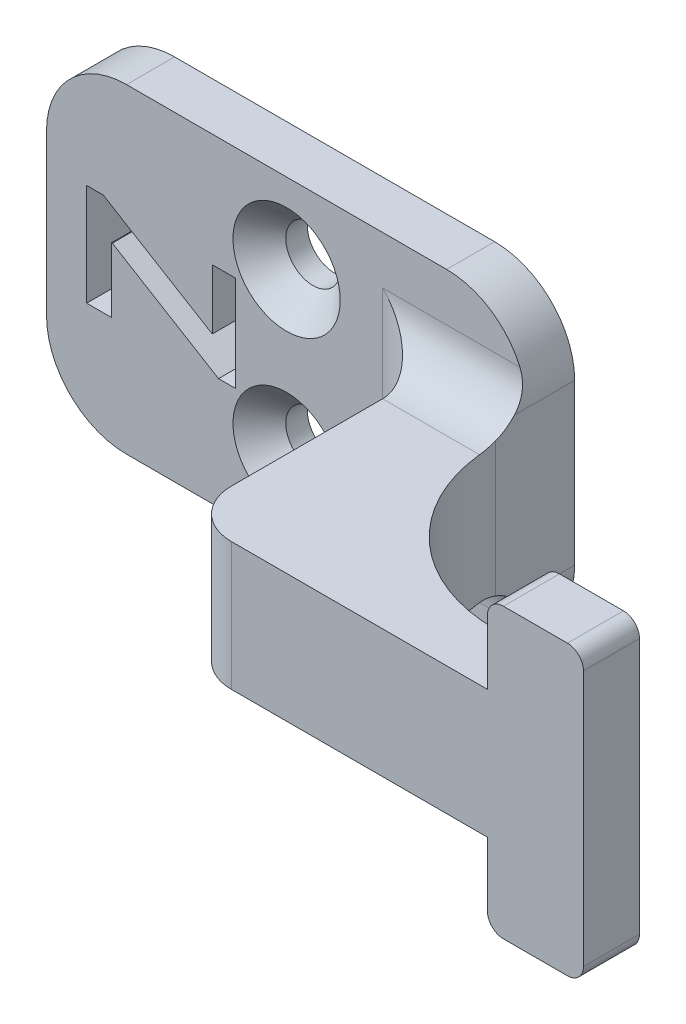
from build123d import *

# Parameters (mm, degrees)
BOSS_EXTRUDE1_DEPTH                                 = 3
BOSS_EXTRUDE2_DEPTH                                 = 4
SKETCH3_W                                           = 6
SKETCH3_H                                           = 5
BOSS_EXTRUDE3_DEPTH                                 = 3.5
FILLET1_R                                           = 3
FILLET3_R                                           = 10
CSK_FOR_M3_COUNTERSUNK_FLAT_HEAD_SCREW1_D           = 3.4
CSK_FOR_M3_COUNTERSUNK_FLAT_HEAD_SCREW1_DEPTH       = 20
CSK_FOR_M3_COUNTERSUNK_FLAT_HEAD_SCREW1_CSINK_D     = 6.7
CSK_FOR_M3_COUNTERSUNK_FLAT_HEAD_SCREW1_CSINK_ANGLE = 90
CSK_FOR_M3_COUNTERSUNK_FLAT_HEAD_SCREW1_TIP         = 1.021463052
CUT_EXTRUDE1_DEPTH                                  = 10
FILLET4_R                                           = 1


with BuildPart() as part:
    # Sketch1 → Boss-Extrude1 (new body)
    with BuildSketch(Plane.XY):
        with BuildLine():
            Line((-10, -10), (10, -10))
            ThreePointArc((10, -10), (13.535533906, -8.535533906), (15, -5))
            Line((15, -5), (15, 5))
            ThreePointArc((15, 5), (13.535533906, 8.535533906), (10, 10))
            Line((10, 10), (-10, 10))
            ThreePointArc((-10, 10), (-13.535533906, 8.535533906), (-15, 5))
            Line((-15, 5), (-15, -5))
            ThreePointArc((-15, -5), (-13.535533906, -8.535533906), (-10, -10))
        make_face()
    extrude(amount=BOSS_EXTRUDE1_DEPTH)

    # Sketch2 → Boss-Extrude2 (add, symmetric)
    with BuildSketch(Plane(origin=(0, 0, 0), x_dir=(1, 0, 0), z_dir=(0, 1, 0))):
        Polygon((15, 0), (15, -14.95), (34, -14.95), (34, -18.45), (9, -18.45), (9, 0), align=None)
    extrude(amount=BOSS_EXTRUDE2_DEPTH, both=True)

    # Sketch3 → Boss-Extrude3 (add)
    with BuildSketch(Plane.XY.offset(18.45)):
        with Locations((31, 6.5)):
            Rectangle(SKETCH3_W, SKETCH3_H)
        with Locations((31, -6.5)):
            Rectangle(SKETCH3_W, SKETCH3_H)
    extrude(amount=-BOSS_EXTRUDE3_DEPTH)

    # Fillet1
    fillet1_edges = [part.edges().sort_by_distance(p)[0] for p in [
        (12, 4, 3),
        (9, 0, 3),
        (12, -4, 3),
        (9, 0, 18.45),
    ]]
    fillet(fillet1_edges, radius=FILLET1_R)

    # Fillet3
    fillet3_edges = [part.edges().sort_by_distance(p)[0] for p in [
        (15, 0, 14.95),
    ]]
    fillet(fillet3_edges, radius=FILLET3_R)

    # CSK for M3 Countersunk Flat Head Screw1
    with Locations(Plane(origin=(0, 5, 3), x_dir=(1, 0, 0), z_dir=(0, 0, 1))):
        with Locations((0, 0), (0, -10)):
            CounterSinkHole(CSK_FOR_M3_COUNTERSUNK_FLAT_HEAD_SCREW1_D / 2, CSK_FOR_M3_COUNTERSUNK_FLAT_HEAD_SCREW1_CSINK_D / 2, depth=CSK_FOR_M3_COUNTERSUNK_FLAT_HEAD_SCREW1_DEPTH, counter_sink_angle=CSK_FOR_M3_COUNTERSUNK_FLAT_HEAD_SCREW1_CSINK_ANGLE)
            with Locations((0, 0, -(CSK_FOR_M3_COUNTERSUNK_FLAT_HEAD_SCREW1_DEPTH + CSK_FOR_M3_COUNTERSUNK_FLAT_HEAD_SCREW1_TIP / 2))):  # 118° drill point
                Cone(0, CSK_FOR_M3_COUNTERSUNK_FLAT_HEAD_SCREW1_D / 2, CSK_FOR_M3_COUNTERSUNK_FLAT_HEAD_SCREW1_TIP, mode=Mode.SUBTRACT)

    # Sketch6 → Cut-Extrude1 (cut)
    with BuildSketch(Plane.XY.offset(3)):
        Polygon((-3.179643035, 2.933019371), (-4.626512789, 2.933019371), (-4.626512789, -0.799365029), (-4.67476253, -0.799365029), (-11.458554614, 3.29759659), (-12.490123019, 3.29759659), (-12.490123019, -3.072836961), (-10.93658358, -3.072836961), (-10.93658358, 0.975645142), (-10.888042331, 0.975645142), (-4.253108018, -3.036364149), (-3.179643035, -3.036364149), align=None)
    extrude(amount=-CUT_EXTRUDE1_DEPTH, mode=Mode.SUBTRACT)

    # Fillet4
    fillet4_edges = [part.edges().sort_by_distance(p)[0] for p in [
        (34, 9, 16.7),
        (28, 9, 16.7),
        (34, -9, 16.7),
        (28, -9, 16.7),
    ]]
    fillet(fillet4_edges, radius=FILLET4_R)


solid = part.part
